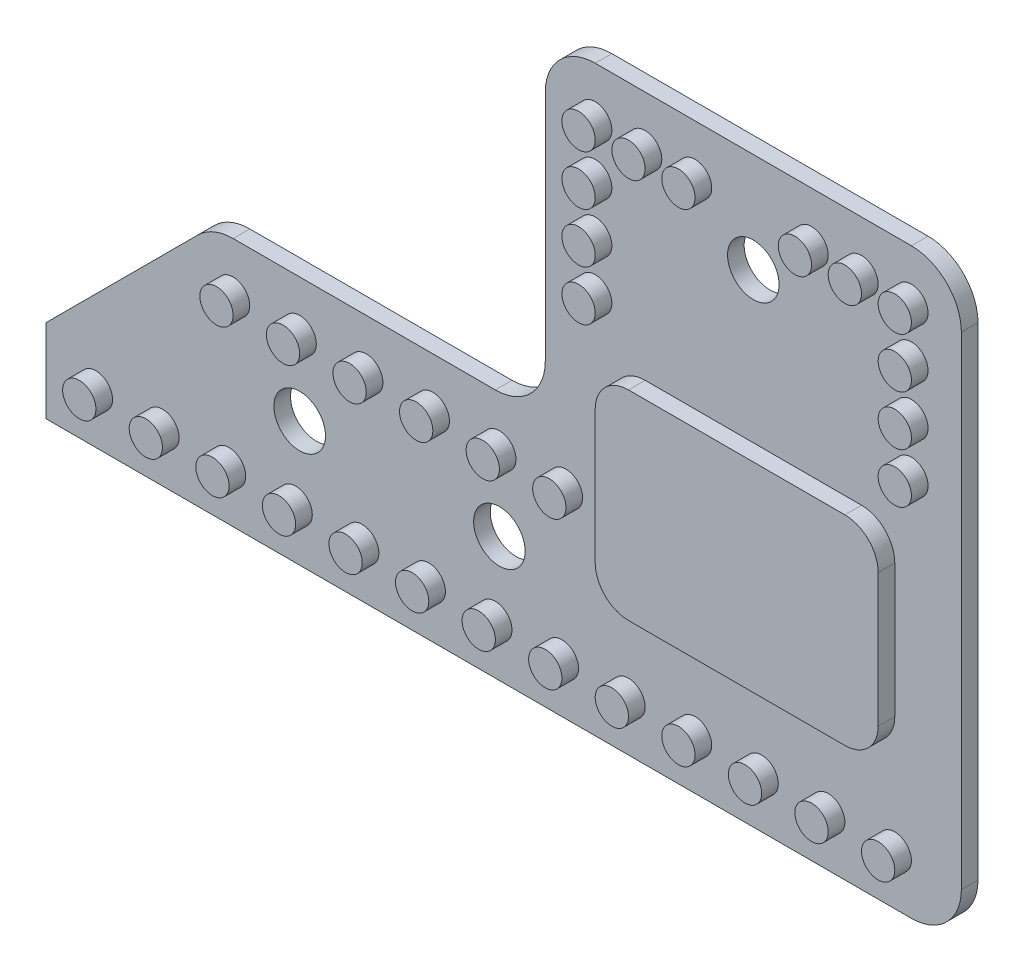
from build123d import *

# Parameters (mm, degrees)
BOSS_EXTRUDE1_DEPTH = 1
SKETCH2_R           = 1
BOSS_EXTRUDE2_DEPTH = 1
FILLET1_R           = 3
CUT_EXTRUDE1_REACH  = 3
SKETCH3_R           = 1.55


with BuildPart() as part:
    # Sketch1 → Boss-Extrude1 (new body)
    with BuildSketch(Plane.XY):
        Polygon((-96, 3), (-41, 3), (-41, 38), (-66, 38), (-66, 18), (-86, 18), (-96, 8), align=None)
    extrude(amount=BOSS_EXTRUDE1_DEPTH)

    # Sketch2 → Boss-Extrude2 (add)
    with BuildSketch(Plane.XY.offset(1)):
        with BuildLine():
            Line((-47, 11), (-60, 11))
            ThreePointArc((-60, 11), (-61.414213562, 11.585786438), (-62, 13))
            Line((-62, 13), (-62, 21))
            ThreePointArc((-62, 21), (-61.414213562, 22.414213562), (-60, 23))
            Line((-60, 23), (-47, 23))
            ThreePointArc((-47, 23), (-45.585786438, 22.414213562), (-45, 21))
            Line((-45, 21), (-45, 13))
            ThreePointArc((-45, 13), (-45.585786438, 11.585786438), (-47, 11))
        make_face()
        with Locations((-63, 26)):
            Circle(SKETCH2_R)
        with Locations((-63, 29)):
            Circle(SKETCH2_R)
        with Locations((-63, 32)):
            Circle(SKETCH2_R)
        with Locations((-63, 35)):
            Circle(SKETCH2_R)
        with Locations((-60, 35)):
            Circle(SKETCH2_R)
        with Locations((-57, 35)):
            Circle(SKETCH2_R)
        with Locations((-50, 35)):
            Circle(SKETCH2_R)
        with Locations((-47, 35)):
            Circle(SKETCH2_R)
        with Locations((-44, 32)):
            Circle(SKETCH2_R)
        with Locations((-44, 29)):
            Circle(SKETCH2_R)
        with Locations((-44, 26)):
            Circle(SKETCH2_R)
        with Locations((-45, 6)):
            Circle(SKETCH2_R)
        with Locations((-49, 6)):
            Circle(SKETCH2_R)
        with Locations((-53, 6)):
            Circle(SKETCH2_R)
        with Locations((-57, 6)):
            Circle(SKETCH2_R)
        with Locations((-61, 6)):
            Circle(SKETCH2_R)
        with Locations((-65, 6)):
            Circle(SKETCH2_R)
        with Locations((-69, 6)):
            Circle(SKETCH2_R)
        with Locations((-73, 6)):
            Circle(SKETCH2_R)
        with Locations((-77, 6)):
            Circle(SKETCH2_R)
        with Locations((-81, 6)):
            Circle(SKETCH2_R)
        with Locations((-85, 6)):
            Circle(SKETCH2_R)
        with Locations((-89, 6)):
            Circle(SKETCH2_R)
        with Locations((-93, 6)):
            Circle(SKETCH2_R)
        with Locations((-84.757359313, 15)):
            Circle(SKETCH2_R)
        with Locations((-76.757359313, 15)):
            Circle(SKETCH2_R)
        with Locations((-72.757359313, 15)):
            Circle(SKETCH2_R)
        with Locations((-68.757359313, 15)):
            Circle(SKETCH2_R)
        with Locations((-64.757359313, 15)):
            Circle(SKETCH2_R)
        with Locations((-44, 35)):
            Circle(SKETCH2_R)
        with Locations((-80.757359313, 15)):
            Circle(SKETCH2_R)
    extrude(amount=BOSS_EXTRUDE2_DEPTH)

    # Fillet1
    fillet1_edges = [part.edges().sort_by_distance(p)[0] for p in [
        (-41, 38, 0.5),
        (-41, 3, 0.5),
        (-86, 18, 0.5),
        (-66, 18, 0.5),
        (-66, 38, 0.5),
    ]]
    fillet(fillet1_edges, radius=FILLET1_R)

    # Sketch3 → Cut-Extrude1 (cut, up to next)
    with BuildSketch(Plane.XY.offset(1), mode=Mode.PRIVATE) as cut_extrude1_sk1:
        with Locations((-53.5, 32)):
            Circle(SKETCH3_R)
    cut_extrude1_tool1 = extrude(cut_extrude1_sk1.sketch, amount=-CUT_EXTRUDE1_REACH, mode=Mode.PRIVATE) & part.part
    add(cut_extrude1_tool1.solids().sort_by_distance((-53.5, 32, 1))[0], mode=Mode.SUBTRACT)
    # Sketch3 → Cut-Extrude1 (cut, up to next)
    with BuildSketch(Plane.XY.offset(1), mode=Mode.PRIVATE) as cut_extrude1_sk2:
        with Locations((-68.757359313, 10.5)):
            Circle(SKETCH3_R)
    cut_extrude1_tool2 = extrude(cut_extrude1_sk2.sketch, amount=-CUT_EXTRUDE1_REACH, mode=Mode.PRIVATE) & part.part
    add(cut_extrude1_tool2.solids().sort_by_distance((-68.757359, 10.5, 1))[0], mode=Mode.SUBTRACT)
    # Sketch3 → Cut-Extrude1 (cut, up to next)
    with BuildSketch(Plane.XY.offset(1), mode=Mode.PRIVATE) as cut_extrude1_sk3:
        with Locations((-80.757359313, 10.5)):
            Circle(SKETCH3_R)
    cut_extrude1_tool3 = extrude(cut_extrude1_sk3.sketch, amount=-CUT_EXTRUDE1_REACH, mode=Mode.PRIVATE) & part.part
    add(cut_extrude1_tool3.solids().sort_by_distance((-80.757359, 10.5, 1))[0], mode=Mode.SUBTRACT)


solid = part.part
